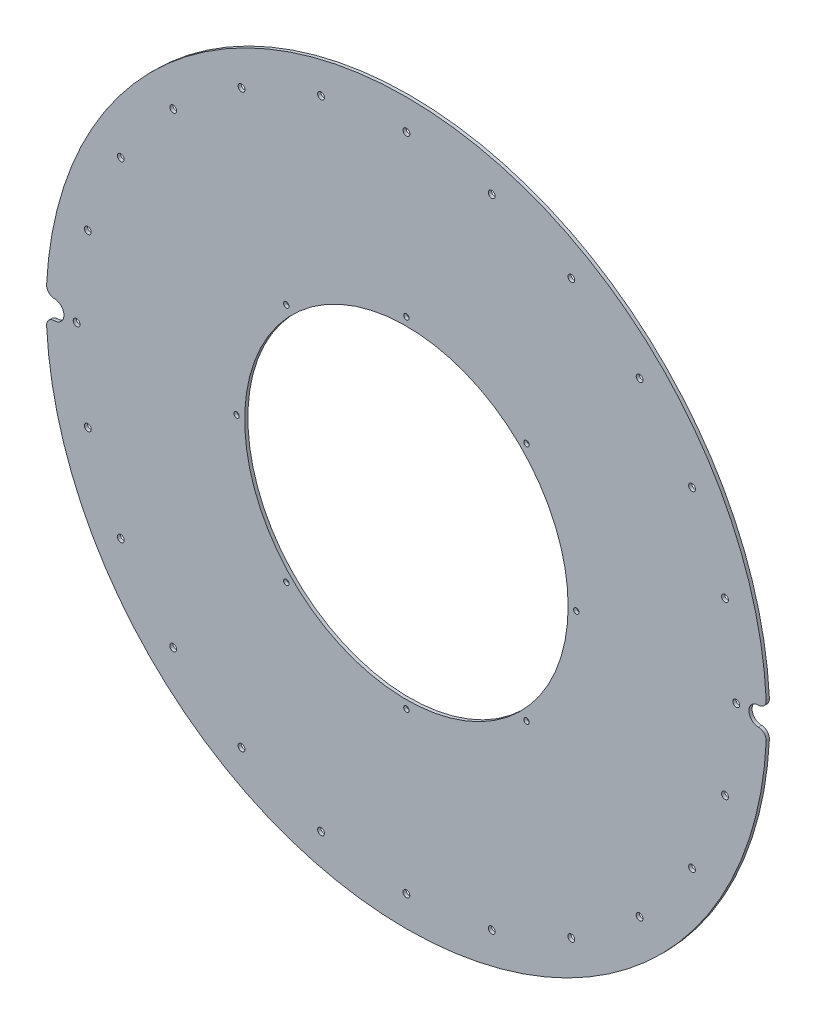
from build123d import *

# Parameters (mm, degrees)
SKETCH1_R            = 227.2
SKETCH1_R_2          = 102
EXTRUDE1_DEPTH       = 2
M4_CLEARANCE_HOLE1_D = 4.3
CIRPATTERN1_COUNT    = 24
M4_CLEARANCE_HOLE2_D = 4.3
M3_CLEARANCE_HOLE1_D = 3.4
CUT_EXTRUDE2_DEPTH   = 3


with BuildPart() as part:
    # Sketch1 → Extrude1 (new body)
    with BuildSketch(Plane.XY):
        Circle(SKETCH1_R)
        Circle(SKETCH1_R_2, mode=Mode.SUBTRACT)
    extrude(amount=EXTRUDE1_DEPTH)

    # M4 Clearance Hole1 (through all)
    with Locations(Plane(origin=(0, 0, 0), x_dir=(-1, 0, 0), z_dir=(0, 0, -1))):
        with Locations((0, 208)):
            m4_clearance_hole1 = Hole(M4_CLEARANCE_HOLE1_D / 2)

    # CirPattern1: M4 Clearance Hole1 ×24 about axis
    cirpattern1_axis = Axis((0, 0, 0), (0, 0, 1))
    for i in range(1, CIRPATTERN1_COUNT):
        add(m4_clearance_hole1.rotate(cirpattern1_axis, i * 360 / CIRPATTERN1_COUNT), mode=Mode.SUBTRACT)

    # M4 Clearance Hole2 (through all)
    with Locations(Plane(origin=(0, 0, 0), x_dir=(-1, 0, 0), z_dir=(0, 0, -1))):
        with Locations((-222, 0), (222, 0)):
            Hole(M4_CLEARANCE_HOLE2_D / 2)

    # M3 Clearance Hole1 (through all)
    with Locations(Plane(origin=(0, 0, 0), x_dir=(-1, 0, 0), z_dir=(0, 0, -1))):
        with Locations((-107.125, 0), (-75.748813935, -75.748813935), (0, -107.125), (75.748813935, -75.748813935), (107.125, 0), (75.748813935, 75.748813935), (0, 107.125), (-75.748813935, 75.748813935)):
            Hole(M3_CLEARANCE_HOLE1_D / 2)

    # Sketch11 → Cut-Extrude2 (cut, through all)
    with BuildSketch(Plane(origin=(0, 0, 0), x_dir=(-1, 0, 0), z_dir=(0, 0, -1))):
        with BuildLine():
            ThreePointArc((222, 6), (216, 0), (222, -6))
            ThreePointArc((222, -6), (225.571486017, -7.531089641), (226.925079563, -11.173552045))
            ThreePointArc((226.925079563, -11.173552045), (227.2, 0), (226.925079563, 11.173552045))
            ThreePointArc((226.925079563, 11.173552045), (225.571486017, 7.531089641), (222, 6))
        make_face()
        with BuildLine():
            ThreePointArc((-222, -6), (-225.571486017, -7.531089641), (-226.925079563, -11.173552045))
            ThreePointArc((-226.925079563, -11.173552045), (-227.2, 0), (-226.925079563, 11.173552045))
            ThreePointArc((-226.925079563, 11.173552045), (-225.571486017, 7.531089641), (-222, 6))
            ThreePointArc((-222, 6), (-216, 0), (-222, -6))
        make_face()
    extrude(amount=-CUT_EXTRUDE2_DEPTH, mode=Mode.SUBTRACT)


solid = part.part
